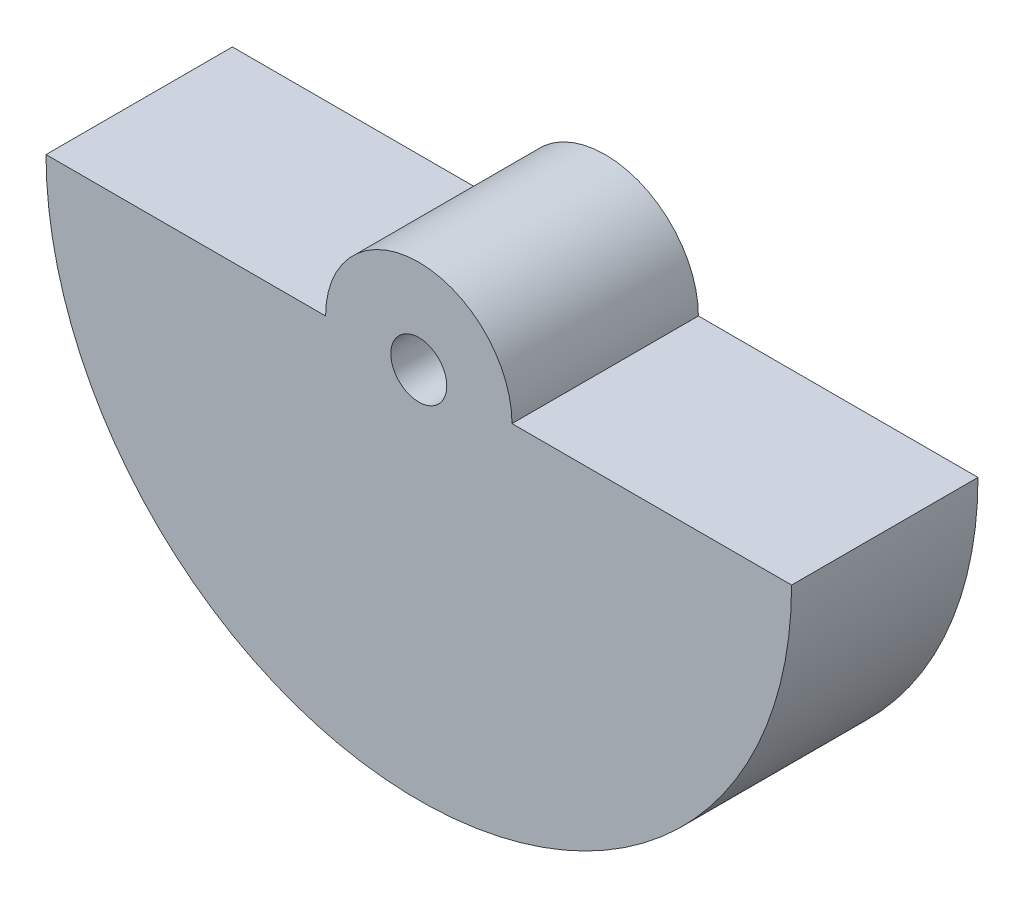
from build123d import *

# Parameters (mm, degrees)
BOSS_EXTRUDE1_DEPTH = 20
SKETCH2_R           = 10
BOSS_EXTRUDE2_DEPTH = 20
SKETCH3_R           = 3
CUT_EXTRUDE1_DEPTH  = 20


with BuildPart() as part:
    # Sketch1 → Boss-Extrude1 (new body)
    with BuildSketch(Plane.XY):
        with BuildLine():
            Line((-3.402685511, 21.555471253), (76.597314489, 21.555471253))
            ThreePointArc((76.597314489, 21.555471253), (36.597314489, -18.444528747), (-3.402685511, 21.555471253))
        make_face()
    extrude(amount=BOSS_EXTRUDE1_DEPTH)

    # Sketch2 → Boss-Extrude2 (add)
    with BuildSketch(Plane(origin=(0, 0, 0), x_dir=(-1, 0, 0), z_dir=(0, 0, -1))):
        with Locations((-36.597314489, 21.555471253)):
            Circle(SKETCH2_R)
    extrude(amount=-BOSS_EXTRUDE2_DEPTH)

    # Sketch3 → Cut-Extrude1 (cut)
    with BuildSketch(Plane(origin=(0, 0, 0), x_dir=(-1, 0, 0), z_dir=(0, 0, -1))):
        with Locations((-36.597314489, 21.555471253)):
            Circle(SKETCH3_R)
    extrude(amount=-CUT_EXTRUDE1_DEPTH, mode=Mode.SUBTRACT)


solid = part.part
